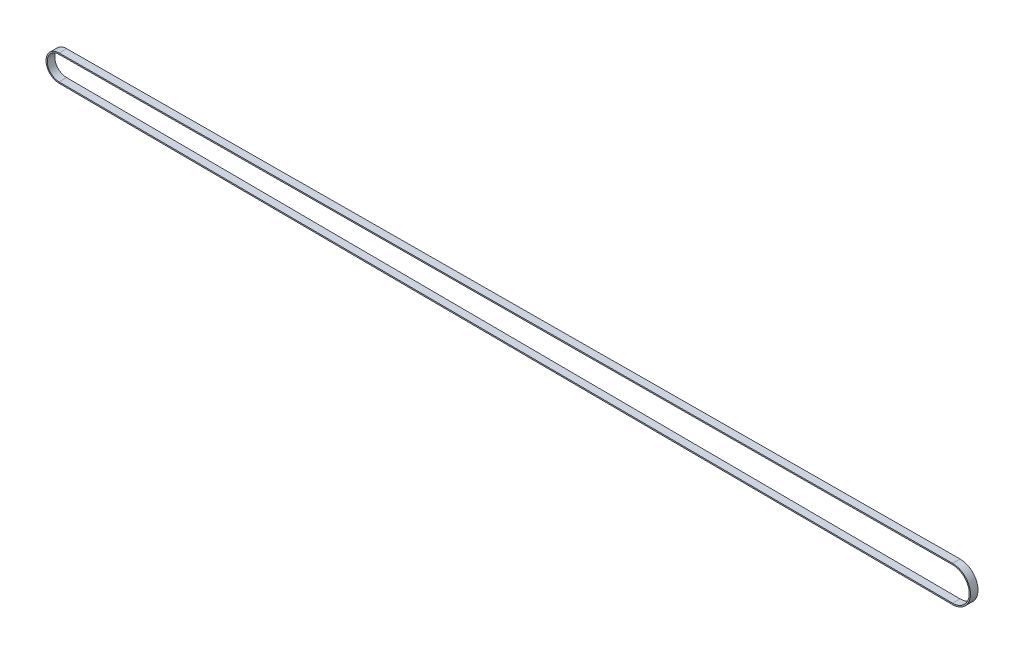
from build123d import *

# Parameters (mm, degrees)
EXTRU_MINCE1_DEPTH = 3


with BuildPart() as part:
    # Esquisse2 → Extru.-Mince1 (new body)
    with BuildSketch(Plane.XY.offset(331.056465315)):
        with BuildLine():
            Line((-363.096783497, 1.761494352), (-6.106895541, 3.661467443))
            ThreePointArc((-6.106895541, 3.661467443), (1.08115768, -3.488431294), (-6.106895541, -10.638330031))
            Line((-6.106895541, -10.638330031), (-363.096783497, -8.738356941))
            ThreePointArc((-363.096783497, -8.738356941), (-368.31884232, -3.488431294), (-363.096783497, 1.761494352))
        make_face()
        with BuildLine():
            Line((-363.094122432, 1.261501433), (-6.104234477, 3.161474524))
            ThreePointArc((-6.104234477, 3.161474524), (0.58115768, -3.488431294), (-6.104234477, -10.138337113))
            Line((-6.104234477, -10.138337113), (-363.094122432, -8.238364022))
            ThreePointArc((-363.094122432, -8.238364022), (-367.81884232, -3.488431294), (-363.094122432, 1.261501433))
        make_face(mode=Mode.SUBTRACT)
    extrude(amount=-EXTRU_MINCE1_DEPTH)


solid = part.part
